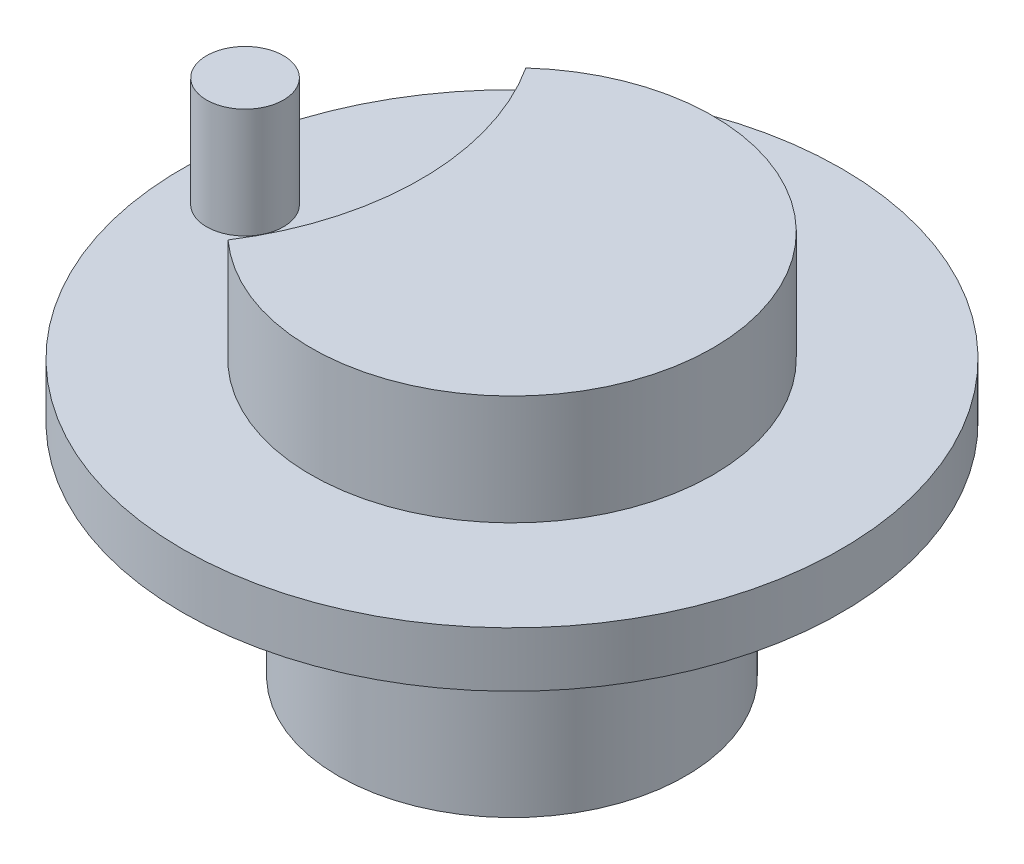
from build123d import *

# Parameters (mm, degrees)
CROQUIS1_R              = 15
SALIENTE_EXTRUIR1_DEPTH = 2.5
SALIENTE_EXTRUIR2_START = 2.5
CROQUIS1_4_R            = 1.75
SALIENTE_EXTRUIR2_DEPTH = 5
CROQUIS2_R              = 7.9
SALIENTE_EXTRUIR3_DEPTH = 10


with BuildPart() as part:
    # Croquis1 → Saliente-Extruir1 (new body)
    with BuildSketch(Plane(origin=(0, 0, 0), x_dir=(1, 0, 0), z_dir=(0, 1, 0))):
        with Locations(Location((0, 0, 0), (0, 0, 270))):
            Circle(CROQUIS1_R)
    extrude(amount=SALIENTE_EXTRUIR1_DEPTH)

    # Croquis1_4 → Saliente-Extruir2 (add)
    with BuildSketch(Plane(origin=(0, 0, 0), x_dir=(1, 0, 0), z_dir=(0, 1, 0)).offset(SALIENTE_EXTRUIR2_START)):
        with Locations(Location((-12.15, 0, 0), (0, 0, 270))):
            Circle(CROQUIS1_4_R)
        with BuildLine():
            ThreePointArc((-6.146996997, -6.777678653), (9.15, 0), (-6.146996997, 6.777678653))
            ThreePointArc((-6.146996997, 6.777678653), (-4.15, 0), (-6.146996997, -6.777678653))
        make_face()
    extrude(amount=SALIENTE_EXTRUIR2_DEPTH)

    # Croquis2 → Saliente-Extruir3 (add)
    with BuildSketch(Plane.XZ):
        with Locations(Location((0, 0, 0), (0, 0, 90))):
            Circle(CROQUIS2_R)
    extrude(amount=SALIENTE_EXTRUIR3_DEPTH)


solid = part.part
